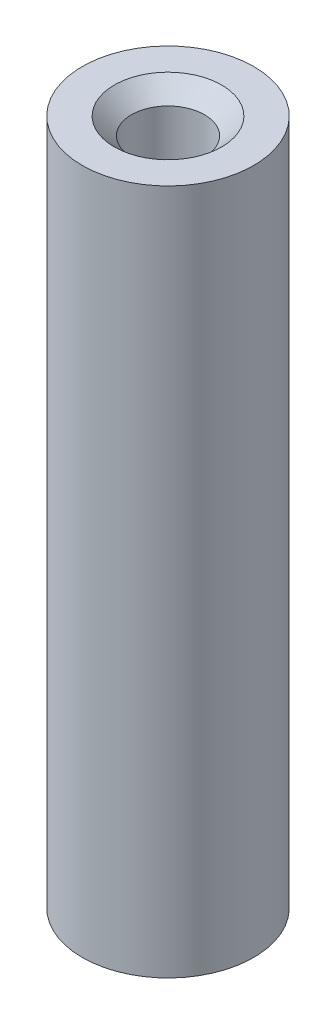
from build123d import *

# Parameters (mm, degrees)
SKETCH1_R           = 3.175
BOSS_EXTRUDE1_DEPTH = 25.4


with BuildPart() as part:
    # Sketch1 → Boss-Extrude1 (new body)
    with BuildSketch(Plane(origin=(0, 0, 0), x_dir=(1, 0, 0), z_dir=(0, 1, 0))):
        Circle(SKETCH1_R)
    extrude(amount=BOSS_EXTRUDE1_DEPTH)

    # Sketch3 → #6-32 Tapped Hole1 (revolve, cut)
    with BuildSketch(Plane(origin=(0, 25.4, 0), x_dir=(0, 0, 1), z_dir=(1, 0, 0))):
        Polygon((0, 0), (0, 25.4), (1.98755, 25.4), (1.35255, 24.765), (1.35255, 0.635), (1.98755, 0), align=None)
    revolve(axis=Axis((0, 31.75, 0), (0, -1, 0)), mode=Mode.SUBTRACT)


solid = part.part
